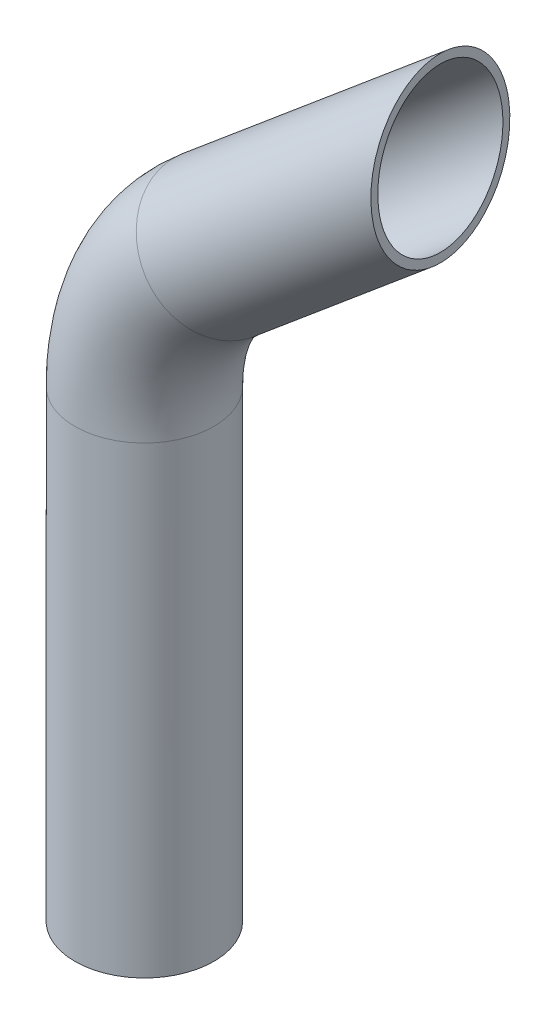
from build123d import *

# Parameters (mm, degrees)
SKETCH3_R               = 30
SKETCH3_R_2             = 27
CUT_EXTRUDE1_DEPTH      = 31.0000001
CUT_EXTRUDE1_DEPTH_BACK = 31.0000001


with BuildPart() as part:
    # Sweep-Thin1: sweep along a path in Sketch1
    with BuildLine(Plane.XY) as sweep_thin1_path:
        Line((0, 0), (0, 200))
        ThreePointArc((0, 200), (8.432299167, 238.035643557), (32.149115128, 268.943999881))
        Line((32.149115128, 268.943999881), (147.055781596, 365.362141334))
    # Sketch3 → Sweep-Thin1 (sweep)
    with BuildSketch(Plane(origin=(0, 0, 0), x_dir=(1, 0, 0), z_dir=(0, 1, 0))):
        Circle(SKETCH3_R)
        Circle(SKETCH3_R_2, mode=Mode.SUBTRACT)
    sweep(path=sweep_thin1_path.line)

    # Sketch4 → Cut-Extrude1 (cut, two sides)
    with BuildSketch(Plane.XY) as cut_extrude1_sk:
        Polygon((127.772153305, 388.343474627), (127.772153305, 310.019037267), (166.339409887, 342.38080804), align=None)
    extrude(amount=CUT_EXTRUDE1_DEPTH, mode=Mode.SUBTRACT)
    extrude(cut_extrude1_sk.sketch, amount=-CUT_EXTRUDE1_DEPTH_BACK, mode=Mode.SUBTRACT)


solid = part.part
